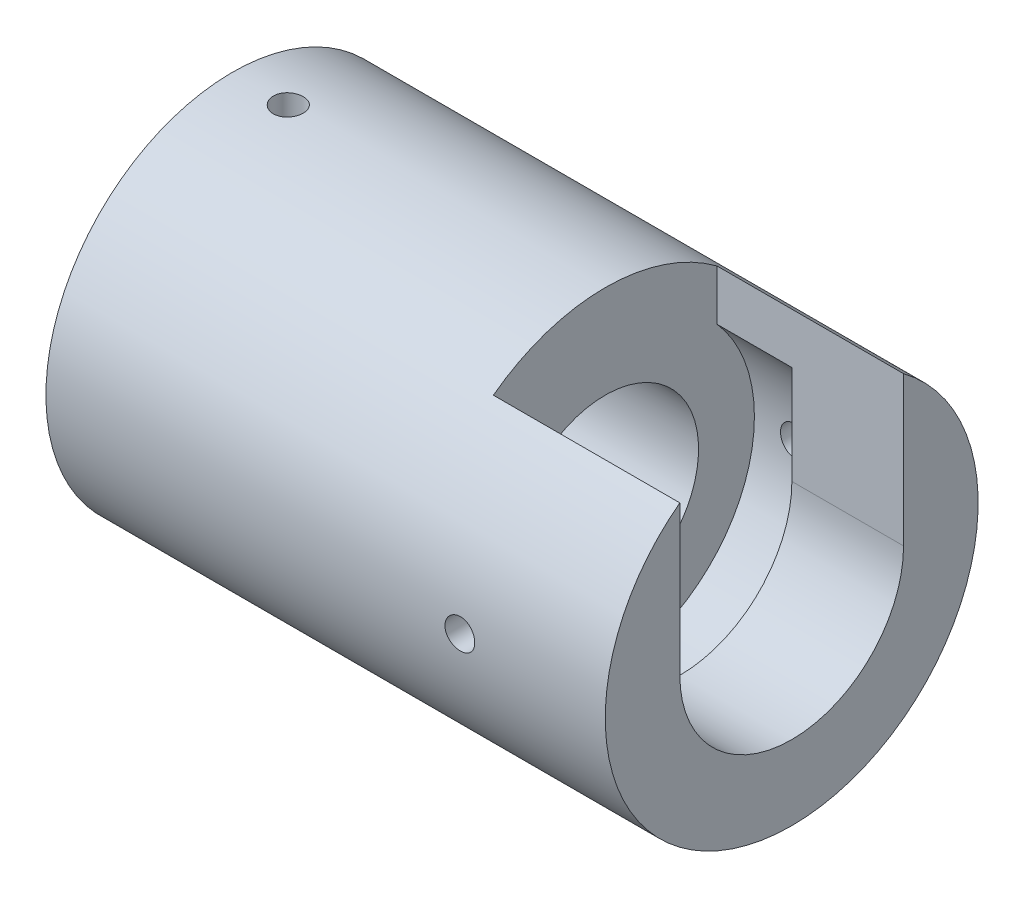
from build123d import *

# Parameters (mm, degrees)
SKETCH1_R                  = 10
BOSS_EXTRUDE1_DEPTH        = 30
SKETCH2_R                  = 5.005
CUT_EXTRUDE1_DEPTH         = 20
CUT_EXTRUDE2_DEPTH         = 10
SKETCH4_R                  = 8
CUT_EXTRUDE3_DEPTH         = 4.01
M2X0_4_TAPPED_HOLE1_REACH  = 39.417
M2X0_4_TAPPED_HOLE1_BORE_R = 0.8
M2X0_4_TAPPED_HOLE2_D      = 1.6
M2X0_4_TAPPED_HOLE3_D      = 1.6
M2X0_4_TAPPED_HOLE4_REACH  = 39.417
M2X0_4_TAPPED_HOLE4_BORE_R = 0.8


with BuildPart() as part:
    # Sketch1 → Boss-Extrude1 (new body)
    with BuildSketch(Plane(origin=(0, 0, 0), x_dir=(0, 0, -1), z_dir=(1, 0, 0))):
        Circle(SKETCH1_R)
    extrude(amount=BOSS_EXTRUDE1_DEPTH)

    # Sketch2 → Cut-Extrude1 (cut)
    with BuildSketch(Plane.ZY):
        Circle(SKETCH2_R)
    extrude(amount=-CUT_EXTRUDE1_DEPTH, mode=Mode.SUBTRACT)

    # Sketch3 → Cut-Extrude2 (cut)
    with BuildSketch(Plane(origin=(30, 0, 0), x_dir=(0, 0, -1), z_dir=(1, 0, 0))):
        with BuildLine():
            Line((-6, 0), (-6, 8))
            ThreePointArc((-6, 8), (0, 10), (6, 8))
            Line((6, 8), (6, 0))
            ThreePointArc((6, 0), (0, -6), (-6, 0))
        make_face()
    extrude(amount=-CUT_EXTRUDE2_DEPTH, mode=Mode.SUBTRACT)

    # Sketch4 → Cut-Extrude3 (cut)
    with BuildSketch(Plane(origin=(20, 0, 0), x_dir=(0, 0, -1), z_dir=(1, 0, 0))):
        Circle(SKETCH4_R)
    extrude(amount=CUT_EXTRUDE3_DEPTH, mode=Mode.SUBTRACT)

    # M2x0.4 Tapped Hole1 bore → M2x0.4 Tapped Hole1 (cut, up to next)
    with BuildSketch(Plane(origin=(0, 0, -10), x_dir=(1, 0, 0), z_dir=(0, 0, -1)), mode=Mode.PRIVATE) as m2x0_4_tapped_hole1_sk1:
        with Locations((22.2, 0)):
            Circle(M2X0_4_TAPPED_HOLE1_BORE_R)
    m2x0_4_tapped_hole1_tool1 = extrude(m2x0_4_tapped_hole1_sk1.sketch, amount=-M2X0_4_TAPPED_HOLE1_REACH, mode=Mode.PRIVATE) & part.part
    add(m2x0_4_tapped_hole1_tool1.solids().sort_by_distance((22.2, 0, -10))[0], mode=Mode.SUBTRACT)

    # M2x0.4 Tapped Hole2 (through all)
    with Locations(Plane.XY.offset(10)):
        with Locations((22.2, 0)):
            Hole(M2X0_4_TAPPED_HOLE2_D / 2)

    # M2x0.4 Tapped Hole3 (through all)
    with Locations(Plane.XZ.offset(10)):
        with Locations((22.2, 0)):
            Hole(M2X0_4_TAPPED_HOLE3_D / 2)

    # M2x0.4 Tapped Hole4 bore → M2x0.4 Tapped Hole4 (cut, up to next)
    with BuildSketch(Plane(origin=(0, 10, 0), x_dir=(1, 0, 0), z_dir=(0, 1, 0)), mode=Mode.PRIVATE) as m2x0_4_tapped_hole4_sk1:
        with Locations((3, 0)):
            Circle(M2X0_4_TAPPED_HOLE4_BORE_R)
    m2x0_4_tapped_hole4_tool1 = extrude(m2x0_4_tapped_hole4_sk1.sketch, amount=-M2X0_4_TAPPED_HOLE4_REACH, mode=Mode.PRIVATE) & part.part
    add(m2x0_4_tapped_hole4_tool1.solids().sort_by_distance((3, 10, 0))[0], mode=Mode.SUBTRACT)


solid = part.part
